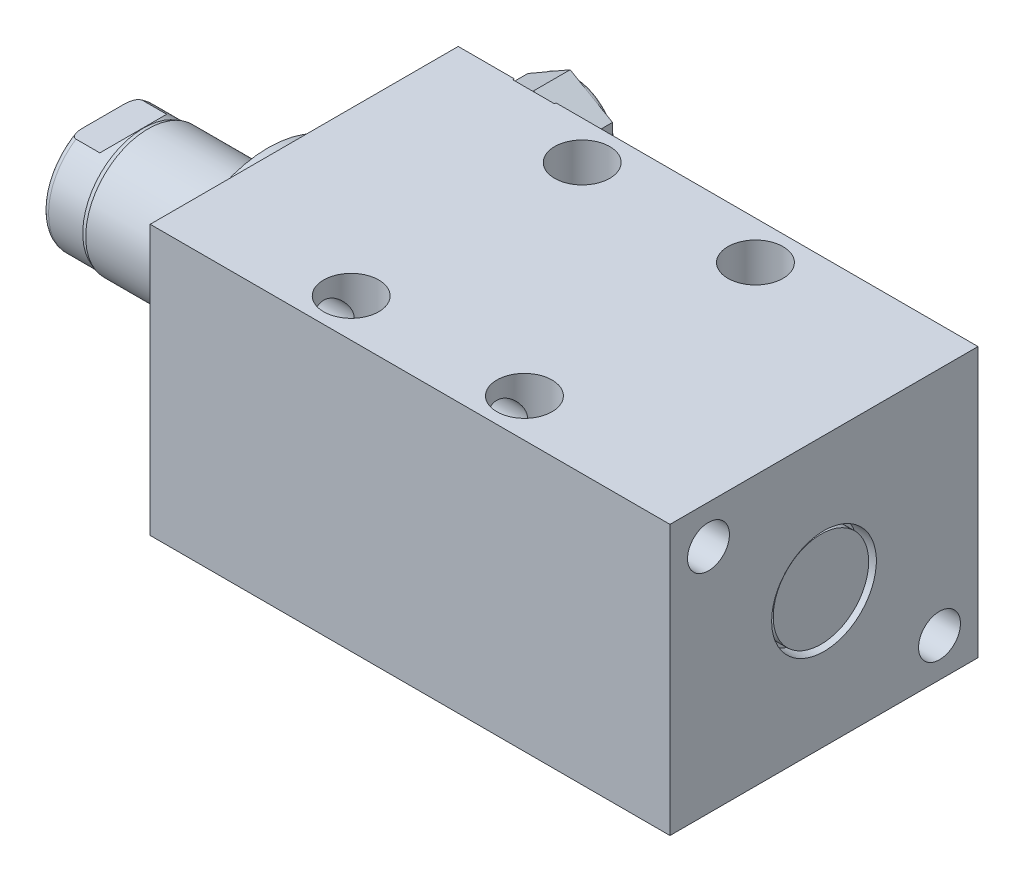
from build123d import *

# Parameters (mm, degrees)
SKETCH1_W            = 50.8
SKETCH1_H            = 44.45
EXTRUDE1_DEPTH       = 85.725
LPATTERN1_COUNT      = 2
LPATTERN1_PITCH      = 57.15
LPATTERN1_COUNT_DIR2 = 2
LPATTERN1_PITCH_DIR2 = 14.3
SKETCH5_R            = 17.4625
EXTRUDE2_DEPTH       = 5.969
SKETCH6_W            = 10.30605
SKETCH6_H            = 27.178
CUT_EXTRUDE4_DEPTH   = 30.48
HOLE1_D              = 6.909
HOLE1_DEPTH          = 85.725
HOLE2_D              = 9.093
HOLE2_DEPTH          = 44.45
EXTRUDE3_DEPTH       = 6.78
SKETCH21_R           = 7.874
EXTRUDE4_DEPTH       = 2.54
LPATTERN2_COUNT      = 2
LPATTERN2_PITCH      = 28.575


with BuildPart() as part:
    # Sketch1 → Extrude1 (new body)
    with BuildSketch(Plane(origin=(0, 0, 0), x_dir=(0, 0, -1), z_dir=(1, 0, 0))):
        Rectangle(SKETCH1_W, SKETCH1_H)
    extrude(amount=EXTRUDE1_DEPTH)

    # S2D0002 → Cut-Revolve1 (revolve, cut)
    with BuildSketch(Plane(origin=(0, 14.3, 0), x_dir=(-1, 0, 0), z_dir=(0, 1, 0)), mode=Mode.PRIVATE) as cut_revolve1_sk:
        Polygon((-17.7165, -25.146), (-21.336, -25.146), (-21.336, -25.4), (-12.7, -25.4), (-12.7, -11.684), (-17.1196, -11.684), (-17.1196, -24.5237), (-17.7165, -25.1206), align=None)
    cut_revolve1 = revolve(cut_revolve1_sk.sketch.rotate(Axis((12.7, 14.3, -19.13842003), (0, 0, 1)), 180), axis=Axis((12.7, 14.3, -19.13842003), (0, 0, 1)), mode=Mode.SUBTRACT)  # turned: the seam where the file's is

    # LPattern1: Cut-Revolve1 2 × 2, 2 skipped
    with Locations(*[(i * LPATTERN1_PITCH, -j * LPATTERN1_PITCH_DIR2, 0) for i in range(LPATTERN1_COUNT) for j in range(LPATTERN1_COUNT_DIR2) if (i, j) not in ((0, 0), (0, 1), (1, 0))]):
        add(cut_revolve1, mode=Mode.SUBTRACT)

    # Sketch5 → Extrude2 (add)
    with BuildSketch(Plane.ZY):
        with Locations(Location((0, 0, 0), (0, 0, 180))):  # turned: the seam where the file's is
            Circle(SKETCH5_R)
    extrude(amount=EXTRUDE2_DEPTH)

    # Sketch6 → Revolve1 (revolve)
    with BuildSketch(Plane(origin=(0, 0, 0), x_dir=(0, 0, 1), z_dir=(0, -1, 0))):
        with Locations((-5.153025, 19.558)):
            Rectangle(SKETCH6_W, SKETCH6_H)
    revolve(axis=Axis((5.754582971, 0, 0), (-1, 0, 0)))

    # S2D0001 → Cut-Revolve4 (revolve, cut)
    with BuildSketch(Plane(origin=(-18.511260017, 3.2639, 0), x_dir=(0, 1, 0), z_dir=(0, 0, 1)), mode=Mode.PRIVATE) as cut_revolve4_sk:
        Polygon((0.1271, 12.920143658), (0.1271, -0.304260017), (-3.2639, -0.304260017), (-3.2639, 14.635739983), (1.1176, 14.635739983), align=None)
    revolve(cut_revolve4_sk.sketch.rotate(Axis((0, 0, 0), (-1, 0, 0)), 90), axis=Axis((0, 0, 0), (-1, 0, 0)), mode=Mode.SUBTRACT)  # turned: the seam where the file's is

    # Sketch8 → Cut-Revolve5 (revolve, cut)
    with BuildSketch(Plane(origin=(0, 0, 0), x_dir=(0, 0, -1), z_dir=(0, 1, 0)), mode=Mode.PRIVATE) as cut_revolve5_sk:
        with BuildLine():
            Line((-10.30605, 25.73), (-10.033, 26.492))
            Line((-10.033, 26.492), (-10.033, 32.131))
            ThreePointArc((-10.033, 32.131), (-9.73542049, 32.84942049), (-9.017, 33.147))
            Line((-9.017, 33.147), (-10.30605, 33.147))
            Line((-10.30605, 33.147), (-10.30605, 25.73))
        make_face()
    revolve(cut_revolve5_sk.sketch.rotate(Axis((-12.65936, 0, 0), (-1, 0, 0)), 180), axis=Axis((-12.65936, 0, 0), (-1, 0, 0)), mode=Mode.SUBTRACT)  # turned: the seam where the file's is

    # Sketch12 → Cut-Extrude4 (cut, symmetric)
    with BuildSketch(Plane(origin=(0, 0, 0), x_dir=(0, -1, 0), z_dir=(0, 0, -1))):
        Polygon((8.382, 33.147), (8.382, 28.194), (10.033, 26.543), (10.033, 33.147), align=None)
        Polygon((-8.382, 33.147), (-8.382, 28.194), (-10.033, 26.543), (-10.033, 33.147), align=None)
    extrude(amount=CUT_EXTRUDE4_DEPTH, both=True, mode=Mode.SUBTRACT)

    # Hole1
    with Locations(Plane.ZY):
        with Locations((-19.05, -15.875), (19.05, 15.875)):
            Hole(HOLE1_D / 2, depth=HOLE1_DEPTH)

    # Hole2
    with Locations(Plane(origin=(0, 22.225, 0), x_dir=(-1, 0, 0), z_dir=(0, 1, 0))):
        with Locations((-26.797, -19.05), (-26.797, 19.05)):
            hole2 = Hole(HOLE2_D / 2, depth=HOLE2_DEPTH)

    # Sketch18 → Extrude3 (add)
    with BuildSketch(Plane(origin=(0, 0, -25.146), x_dir=(-1, 0, 0), z_dir=(0, 0, -1))):
        Polygon((-5.715, 18.33279163), (-12.7, 22.365583261), (-19.685, 18.33279163), (-19.685, 10.26720837), (-12.7, 6.234416739), (-5.715, 10.26720837), align=None)
    extrude(amount=EXTRUDE3_DEPTH)

    # Sketch19 → Cut-Revolve6 (revolve, cut)
    with BuildSketch(Plane(origin=(0, 14.3, 0), x_dir=(-1, 0, 0), z_dir=(0, 1, 0)), mode=Mode.PRIVATE) as cut_revolve6_sk:
        with BuildLine():
            Line((-18.923, -31.926), (-18.923, -34.339))
            Line((-18.923, -34.339), (-22.098, -34.339))
            Line((-22.098, -34.339), (-22.098, -31.164))
            Line((-22.098, -31.164), (-19.685, -31.164))
            ThreePointArc((-19.685, -31.164), (-19.461815367, -31.702815367), (-18.923, -31.926))
        make_face()
    revolve(cut_revolve6_sk.sketch.rotate(Axis((12.7, 14.3, -18.51025594), (0, 0, -1)), 180), axis=Axis((12.7, 14.3, -18.51025594), (0, 0, -1)), mode=Mode.SUBTRACT)  # turned: the seam where the file's is

    # Sketch20 → Cut-Revolve7 (revolve, cut)
    with BuildSketch(Plane(origin=(0, 0, 0), x_dir=(1, 0, 0), z_dir=(0, 1, 0))):
        Polygon((85.725, 8.636), (82.677, 8.636), (82.677, 5.0165), (82.6516, 5.0165), (82.0547, 4.4196), (72.1106, 4.4196), (72.1106, 0), (85.725, 0), align=None)
    revolve(axis=Axis((0, 0, 0), (1, 0, 0)), mode=Mode.SUBTRACT)

    # Sketch21 → Extrude4 (add)
    with BuildSketch(Plane(origin=(82.677, 0, 0), x_dir=(0, 0, -1), z_dir=(1, 0, 0))):
        Circle(SKETCH21_R)
    extrude(amount=EXTRUDE4_DEPTH)

    # LPattern2: Hole2 ×2
    with Locations(*[(i * LPATTERN2_PITCH, 0, 0) for i in range(1, LPATTERN2_COUNT)]):
        add(hole2, mode=Mode.SUBTRACT)


solid = part.part
